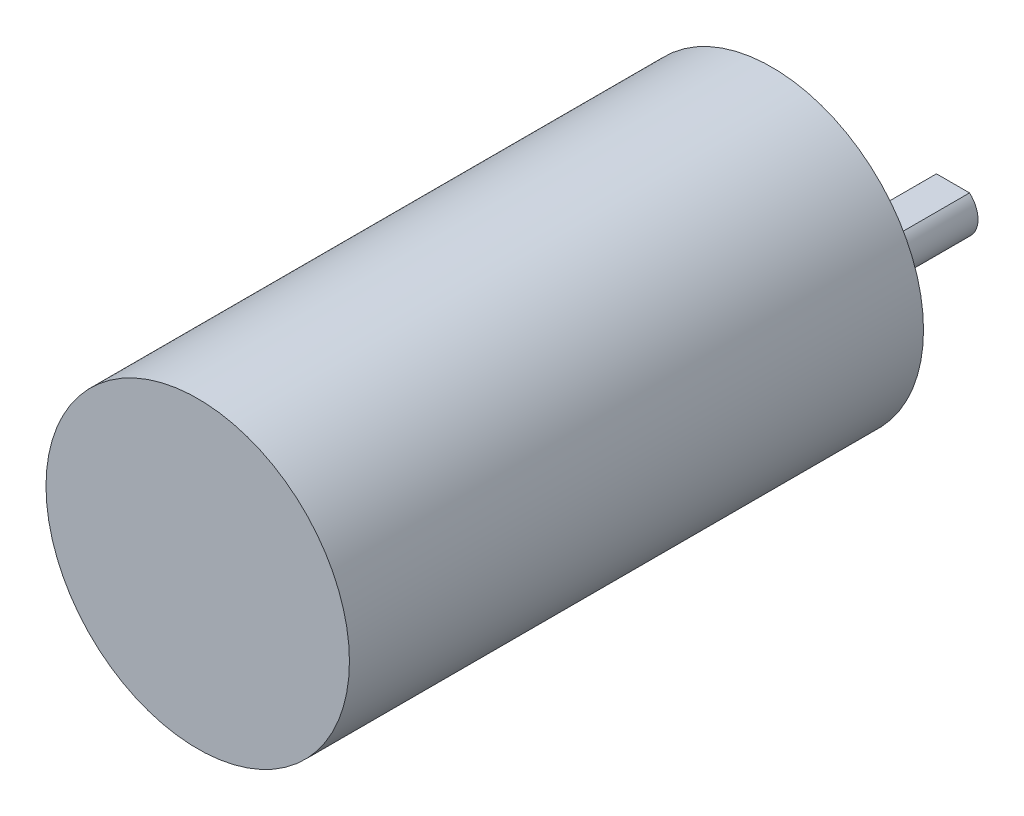
from build123d import *

# Parameters (mm, degrees)
SKETCH1_R           = 18.5
BOSS_EXTRUDE1_DEPTH = 70
SKETCH2_R           = 5.969
BOSS_EXTRUDE2_DEPTH = 6.096
SKETCH3_R           = 3.048
BOSS_EXTRUDE3_DEPTH = 16.002
SKETCH4_R           = 1.6
CUT_EXTRUDE1_DEPTH  = 3
SKETCH5_W           = 4.032124998
SKETCH5_H           = 0.762
CUT_EXTRUDE2_DEPTH  = 16.002


with BuildPart() as part:
    # Sketch1 → Boss-Extrude1 (new body)
    with BuildSketch(Plane.XY):
        Circle(SKETCH1_R)
    extrude(amount=BOSS_EXTRUDE1_DEPTH)

    # Sketch2 → Boss-Extrude2 (add)
    with BuildSketch(Plane(origin=(0, 0, 0), x_dir=(-1, 0, 0), z_dir=(0, 0, -1))):
        with Locations((0, -7.112)):
            Circle(SKETCH2_R)
    extrude(amount=BOSS_EXTRUDE2_DEPTH)

    # Sketch3 → Boss-Extrude3 (add)
    with BuildSketch(Plane(origin=(0, 0, -6.096), x_dir=(-1, 0, 0), z_dir=(0, 0, -1))):
        with Locations((0, -7.112)):
            Circle(SKETCH3_R)
    extrude(amount=BOSS_EXTRUDE3_DEPTH)

    # Sketch4 → Cut-Extrude1 (cut)
    with BuildSketch(Plane(origin=(0, 0, 0), x_dir=(-1, 0, 0), z_dir=(0, 0, -1))):
        with Locations((-15.2766, 0)):
            Circle(SKETCH4_R)
        with Locations((15.2766, 0)):
            Circle(SKETCH4_R)
        with Locations((7.794229315, -13.567540858)):
            Circle(SKETCH4_R)
        with Locations((-7.794229315, -13.567540858)):
            Circle(SKETCH4_R)
        with Locations((-7.794229315, 13.214096537)):
            Circle(SKETCH4_R)
        with Locations((7.794229315, 13.214096537)):
            Circle(SKETCH4_R)
    extrude(amount=-CUT_EXTRUDE1_DEPTH, mode=Mode.SUBTRACT)

    # Sketch5 → Cut-Extrude2 (cut)
    with BuildSketch(Plane(origin=(0, 0, -22.098), x_dir=(-1, 0, 0), z_dir=(0, 0, -1))):
        with Locations((0, -4.445)):
            Rectangle(SKETCH5_W, SKETCH5_H)
    extrude(amount=-CUT_EXTRUDE2_DEPTH, mode=Mode.SUBTRACT)


solid = part.part
